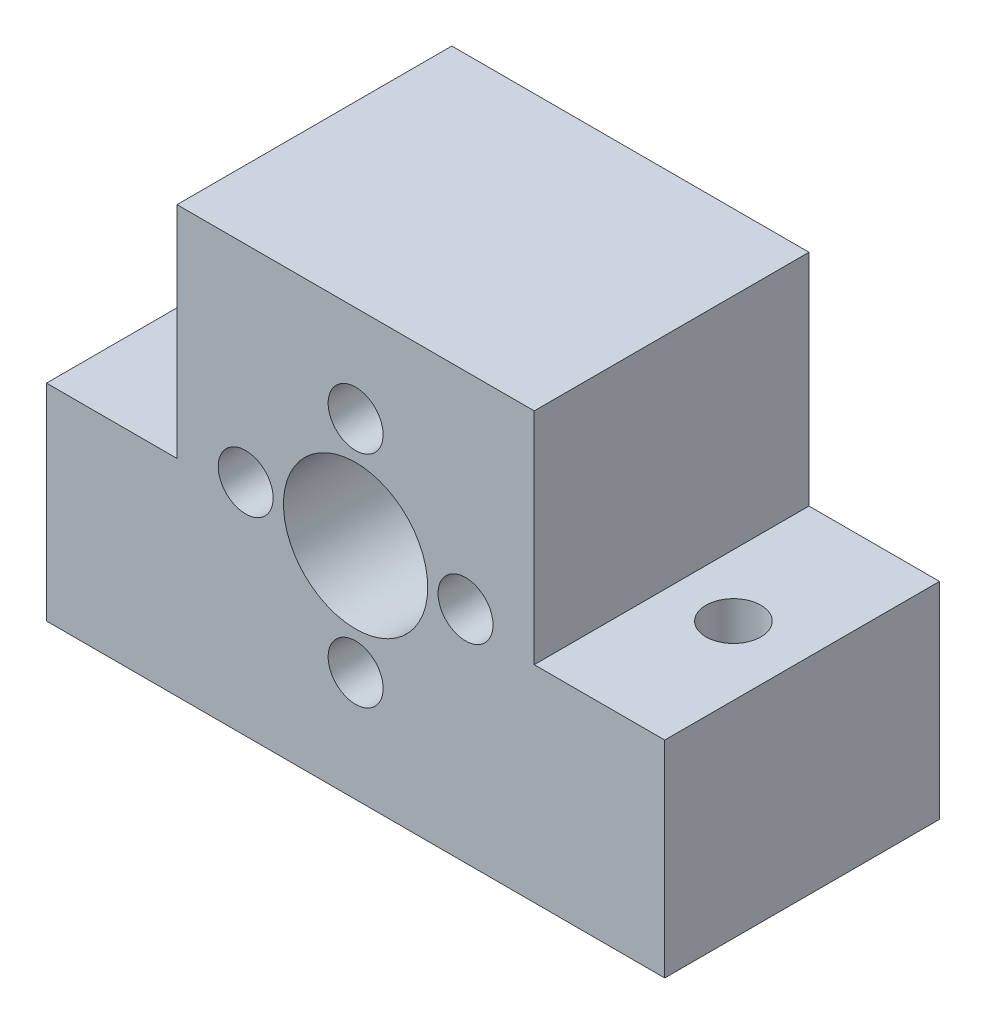
from build123d import *

# Parameters (mm, degrees)
SKETCH1_W           = 45
SKETCH1_H           = 31
SKETCH1_R           = 5.25
SKETCH1_R_2         = 2
BOSS_EXTRUDE1_DEPTH = 20
SKETCH2_R           = 2
CUT_EXTRUDE1_DEPTH  = 32
SKETCH3_W           = 9.5
SKETCH3_H           = 16
CUT_EXTRUDE2_DEPTH  = 21


with BuildPart() as part:
    # Sketch1 → Boss-Extrude1 (new body)
    with BuildSketch(Plane.XY):
        with Locations((0, -0.5)):
            Rectangle(SKETCH1_W, SKETCH1_H)
        Circle(SKETCH1_R, mode=Mode.SUBTRACT)
        with Locations((0, 8)):
            Circle(SKETCH1_R_2, mode=Mode.SUBTRACT)
        with Locations((8, 0)):
            Circle(SKETCH1_R_2, mode=Mode.SUBTRACT)
        with Locations((0, -8)):
            Circle(SKETCH1_R_2, mode=Mode.SUBTRACT)
        with Locations((-8, 0)):
            Circle(SKETCH1_R_2, mode=Mode.SUBTRACT)
    extrude(amount=BOSS_EXTRUDE1_DEPTH)

    # Sketch2 → Cut-Extrude1 (cut, through all)
    with BuildSketch(Plane(origin=(0, 15, 0), x_dir=(1, 0, 0), z_dir=(0, 1, 0))):
        with Locations((-17.5, -10)):
            Circle(SKETCH2_R)
        with Locations((17.5, -10)):
            Circle(SKETCH2_R)
    extrude(amount=-CUT_EXTRUDE1_DEPTH, mode=Mode.SUBTRACT)

    # Sketch3 → Cut-Extrude2 (cut, through all)
    with BuildSketch(Plane(origin=(0, 0, 0), x_dir=(-1, 0, 0), z_dir=(0, 0, -1))):
        with Locations((17.75, 7)):
            Rectangle(SKETCH3_W, SKETCH3_H)
        with Locations((-17.75, 7)):
            Rectangle(SKETCH3_W, SKETCH3_H)
    extrude(amount=-CUT_EXTRUDE2_DEPTH, mode=Mode.SUBTRACT)


solid = part.part
